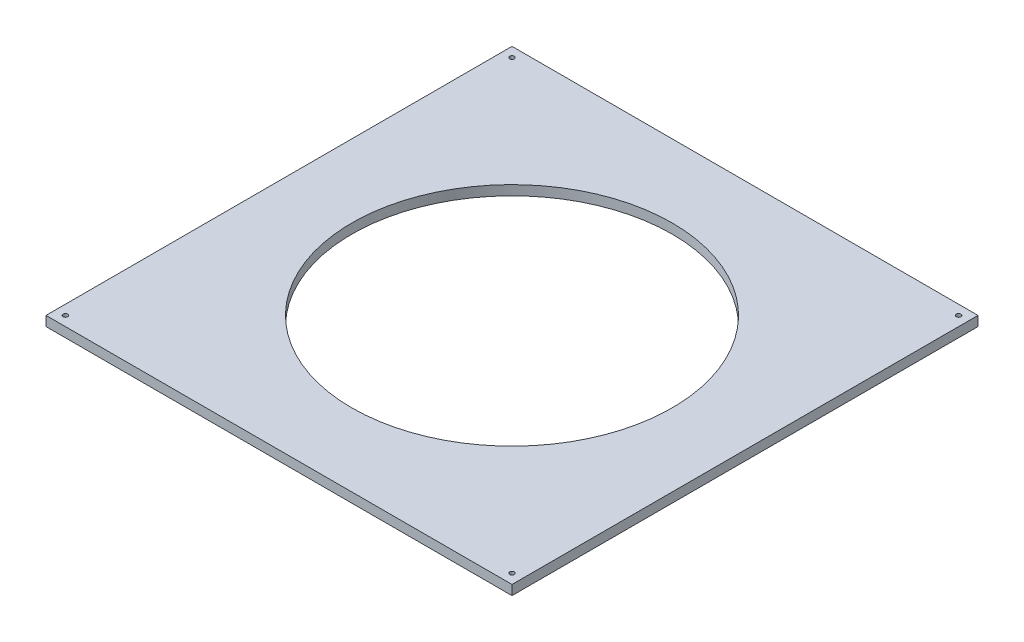
from build123d import *

# Parameters (mm, degrees)
SKETCH1_W           = 609.6
SKETCH1_H           = 609.6
BOSS_EXTRUDE1_DEPTH = 12.7
SKETCH2_R           = 209.55
CUT_EXTRUDE1_DEPTH  = 13.7
SKETCH3_R           = 3
CUT_EXTRUDE2_DEPTH  = 13.7


with BuildPart() as part:
    # Sketch1 → Boss-Extrude1 (new body)
    with BuildSketch(Plane(origin=(0, 0, 0), x_dir=(1, 0, 0), z_dir=(0, 1, 0))):
        with Locations((254.294265396, -260.340726581)):
            Rectangle(SKETCH1_W, SKETCH1_H)
    extrude(amount=BOSS_EXTRUDE1_DEPTH)

    # Sketch2 → Cut-Extrude1 (cut, through all)
    with BuildSketch(Plane(origin=(0, 12.7, 0), x_dir=(1, 0, 0), z_dir=(0, 1, 0))):
        with Locations((254.294265396, -260.340726581)):
            Circle(SKETCH2_R)
    extrude(amount=-CUT_EXTRUDE1_DEPTH, mode=Mode.SUBTRACT)

    # Sketch3 → Cut-Extrude2 (cut, through all)
    with BuildSketch(Plane.XZ):
        with Locations((-37.805734604, 552.440726581)):
            Circle(SKETCH3_R)
        with Locations((546.394265396, 552.440726581)):
            Circle(SKETCH3_R)
        with Locations((546.394265396, -31.759273419)):
            Circle(SKETCH3_R)
        with Locations((-37.805734604, -31.759273419)):
            Circle(SKETCH3_R)
    extrude(amount=-CUT_EXTRUDE2_DEPTH, mode=Mode.SUBTRACT)


solid = part.part
